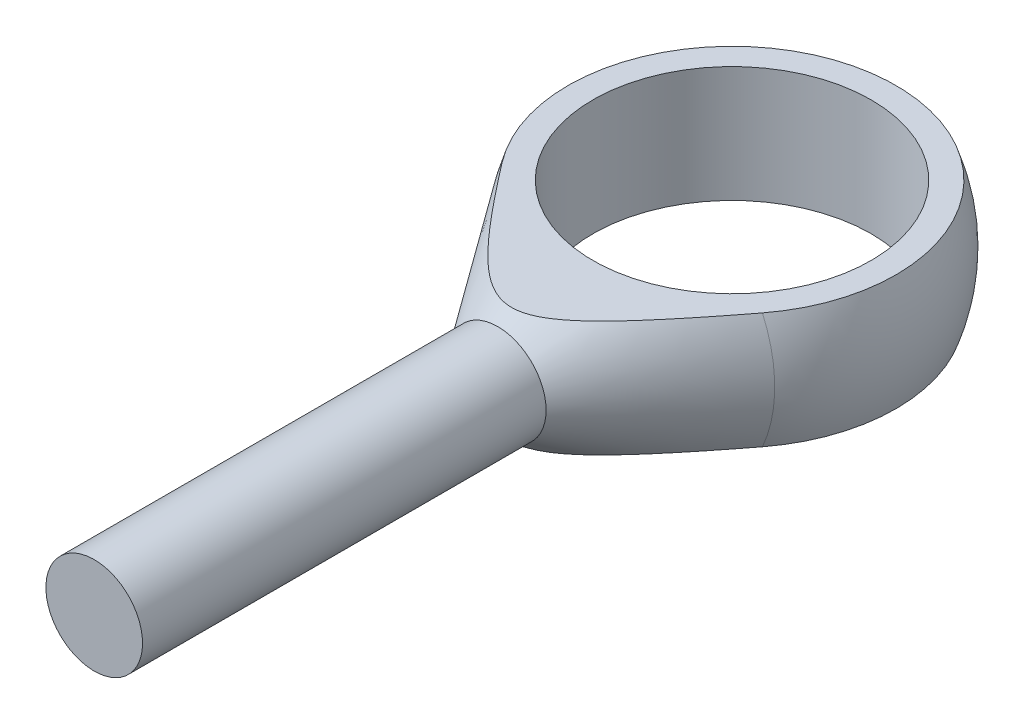
from build123d import *

# Parameters (mm, degrees)
BOSS_EXTRUDE1_REACH     = 44
SKETCH4_R               = 2.5
CUT_EXTRUDE1_DEPTH      = 10
CUT_EXTRUDE1_DEPTH_BACK = 10


with BuildPart() as part:
    # Sketch1 → Revolve1 (revolve)
    with BuildSketch(Plane.XY):
        with BuildLine():
            Line((-8.485281374, 3), (-7.2, 3))
            Line((-7.2, 3), (-7.2, -3))
            Line((-7.2, -3), (-8.485281374, -3))
            ThreePointArc((-8.485281374, -3), (-9, 0), (-8.485281374, 3))
        make_face()
    revolve(axis=Axis((0, -4.387716131, 0), (0, 1, 0)))

    # Sketch4 → Boss-Extrude1 (add, up to next)
    with BuildSketch(Plane.XY.offset(33), mode=Mode.PRIVATE) as boss_extrude1_sk1:
        Circle(SKETCH4_R)
    boss_extrude1_tool1 = extrude(boss_extrude1_sk1.sketch, amount=-BOSS_EXTRUDE1_REACH, mode=Mode.PRIVATE) - part.part
    add(boss_extrude1_tool1.solids().sort_by_distance((0, 0, 33))[0])

    # Sketch5 → Revolve2 (revolve)
    with BuildSketch(Plane(origin=(0, 0, 0), x_dir=(1, 0, 0), z_dir=(0, 1, 0))):
        with BuildLine():
            Line((0, -7.8), (0, -15.691021161))
            Line((0, -15.691021161), (-7.372368399, -5.162187927))
            ThreePointArc((-7.372368399, -5.162187927), (-8.583452557, -2.706352196), (-9, 0))
            Line((-9, 0), (-7.8, 0))
            ThreePointArc((-7.8, 0), (-5.515432893, -5.515432893), (0, -7.8))
        make_face()
    revolve(axis=Axis((0, 0, 0), (0, 0, 1)))

    # Sketch6 → Cut-Extrude1 (cut, two sides)
    with BuildSketch(Plane.ZY) as cut_extrude1_sk:
        Polygon((0, 3), (11.40657714, 3), (12.120651144, 2.5), (12, 3), (12, 13), (0, 13), align=None)
        Polygon((0, -3), (11.40657714, -3), (12.120651144, -2.5), (12, -3), (12, -13), (0, -13), align=None)
    extrude(amount=CUT_EXTRUDE1_DEPTH, mode=Mode.SUBTRACT)
    extrude(cut_extrude1_sk.sketch, amount=-CUT_EXTRUDE1_DEPTH_BACK, mode=Mode.SUBTRACT)


solid = part.part
